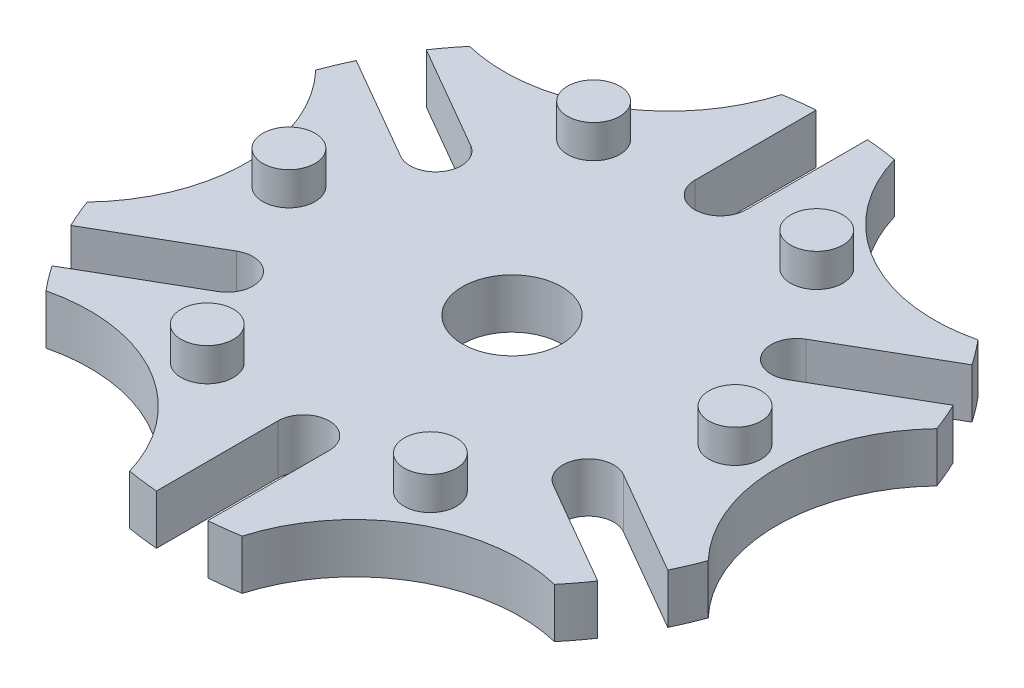
from build123d import *

# Parameters (mm, degrees)
SKETCH1_R           = 15
BOSS_EXTRUDE1_DEPTH = 7.5
SKETCH2_R           = 7.90082564
BOSS_EXTRUDE2_DEPTH = 10


with BuildPart() as part:
    # Sketch1 → Boss-Extrude1 (new body, symmetric)
    with BuildSketch(Plane(origin=(0, 0, 0), x_dir=(1, 0, 0), z_dir=(0, 1, 0))):
        with BuildLine():
            Line((7.75, 99.699235203), (7.75, 63))
            ThreePointArc((7.75, 63), (0, 55.25), (-7.75, 63))
            Line((-7.75, 63), (-7.75, 99.699235203))
            ThreePointArc((-7.75, 99.699235203), (-12.394488334, 99.228910399), (-17.011966007, 98.542341217))
            ThreePointArc((-17.011966007, 98.542341217), (-40, 69.282032303), (-76.834187839, 64.003965339))
            ThreePointArc((-76.834187839, 64.003965339), (-79.737513028, 60.348396964), (-82.467070423, 56.561314481))
            Line((-82.467070423, 56.561314481), (-50.684600438, 38.211696879))
            ThreePointArc((-50.684600438, 38.211696879), (-47.847903559, 35.375), (-46.809600438, 31.5))
            ThreePointArc((-46.809600438, 31.5), (-50.684600438, 24.788303121), (-58.434600438, 24.788303121))
            Line((-58.434600438, 24.788303121), (-90.217070423, 43.137920722))
            ThreePointArc((-90.217070423, 43.137920722), (-92.132001362, 38.880513435), (-93.846153846, 34.538375878))
            ThreePointArc((-93.846153846, 34.538375878), (-80, 0), (-93.846153846, -34.538375878))
            ThreePointArc((-93.846153846, -34.538375878), (-92.132001362, -38.880513435), (-90.217070423, -43.137920722))
            Line((-90.217070423, -43.137920722), (-58.434600438, -24.788303121))
            ThreePointArc((-58.434600438, -24.788303121), (-50.684600438, -24.788303121), (-46.809600438, -31.5))
            ThreePointArc((-46.809600438, -31.5), (-47.847903559, -35.375), (-50.684600438, -38.211696879))
            Line((-50.684600438, -38.211696879), (-82.467070423, -56.561314481))
            ThreePointArc((-82.467070423, -56.561314481), (-79.737513028, -60.348396964), (-76.834187839, -64.003965339))
            ThreePointArc((-76.834187839, -64.003965339), (-40, -69.282032303), (-17.011966007, -98.542341217))
            ThreePointArc((-17.011966007, -98.542341217), (-12.394488334, -99.228910399), (-7.75, -99.699235203))
            Line((-7.75, -99.699235203), (-7.75, -63))
            ThreePointArc((-7.75, -63), (0, -55.25), (7.75, -63))
            Line((7.75, -63), (7.75, -99.699235203))
            ThreePointArc((7.75, -99.699235203), (12.394488334, -99.228910399), (17.011966007, -98.542341217))
            ThreePointArc((17.011966007, -98.542341217), (40, -69.282032303), (76.834187839, -64.003965339))
            ThreePointArc((76.834187839, -64.003965339), (79.737513028, -60.348396964), (82.467070423, -56.561314481))
            Line((82.467070423, -56.561314481), (50.684600438, -38.211696879))
            ThreePointArc((50.684600438, -38.211696879), (47.847903559, -27.625), (58.434600438, -24.788303121))
            Line((58.434600438, -24.788303121), (90.217070423, -43.137920722))
            ThreePointArc((90.217070423, -43.137920722), (92.132001362, -38.880513435), (93.846153846, -34.538375878))
            ThreePointArc((93.846153846, -34.538375878), (80, 0), (93.846153846, 34.538375878))
            ThreePointArc((93.846153846, 34.538375878), (92.132001362, 38.880513435), (90.217070423, 43.137920722))
            Line((90.217070423, 43.137920722), (58.434600438, 24.788303121))
            ThreePointArc((58.434600438, 24.788303121), (47.847903559, 27.625), (50.684600438, 38.211696879))
            Line((50.684600438, 38.211696879), (82.467070423, 56.561314481))
            ThreePointArc((82.467070423, 56.561314481), (79.737513028, 60.348396964), (76.834187839, 64.003965339))
            ThreePointArc((76.834187839, 64.003965339), (40, 69.282032303), (17.011966007, 98.542341217))
            ThreePointArc((17.011966007, 98.542341217), (12.394488334, 99.228910399), (7.75, 99.699235203))
        make_face()
        Circle(SKETCH1_R, mode=Mode.SUBTRACT)
    extrude(amount=BOSS_EXTRUDE1_DEPTH, both=True)

    # Sketch2 → Boss-Extrude2 (add)
    with BuildSketch(Plane(origin=(0, 7.5, 0), x_dir=(1, 0, 0), z_dir=(0, 1, 0))):
        with Locations((33.709720075, 58.386947879)):
            Circle(SKETCH2_R)
        with Locations((67.41944015, 0)):
            Circle(SKETCH2_R)
        with Locations((33.709720075, -58.386947879)):
            Circle(SKETCH2_R)
        with Locations((-33.709720075, -58.386947879)):
            Circle(SKETCH2_R)
        with Locations((-67.41944015, 0)):
            Circle(SKETCH2_R)
        with Locations((-33.709720075, 58.386947879)):
            Circle(SKETCH2_R)
    extrude(amount=BOSS_EXTRUDE2_DEPTH)


solid = part.part
